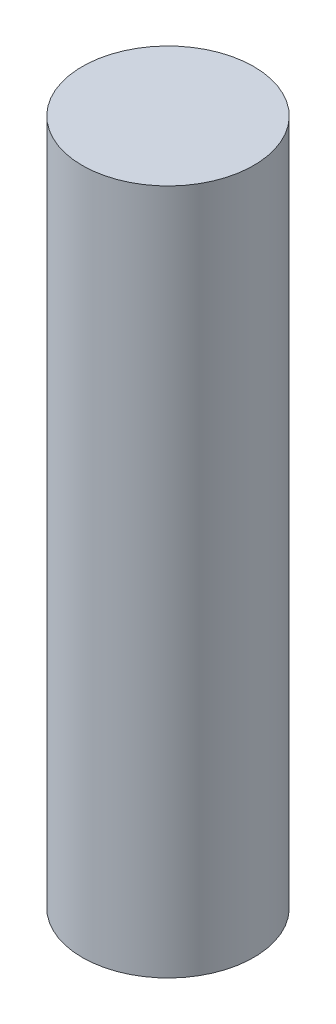
from build123d import *

# Parameters (mm, degrees)
SKETCH1_W = 1.5875
SKETCH1_H = 12.7


with BuildPart() as part:
    # Sketch1 → Revolve1 (revolve)
    with BuildSketch(Plane.XY):
        with Locations((-0.79375, 0)):
            Rectangle(SKETCH1_W, SKETCH1_H)
    revolve(axis=Axis((0, 6.35, 0), (0, 1, 0)))


solid = part.part
